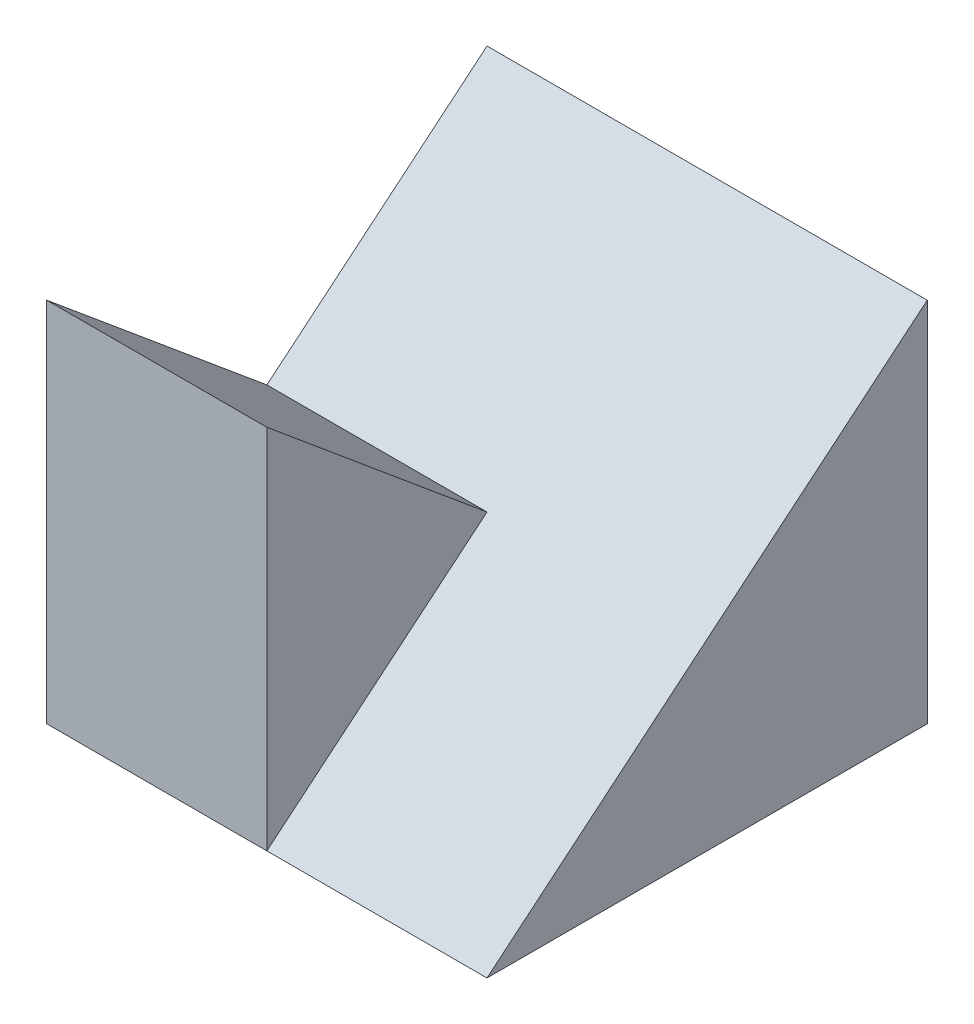
from build123d import *

# Parameters (mm, degrees)
SKETCH1_W           = 6
SKETCH1_H           = 6
BOSS_EXTRUDE1_DEPTH = 5
CUT_EXTRUDE1_DEPTH  = 10
CUT_EXTRUDE2_DEPTH  = 3


with BuildPart() as part:
    # Sketch1 → Boss-Extrude1 (new body)
    with BuildSketch(Plane(origin=(0, 0, 0), x_dir=(1, 0, 0), z_dir=(0, 1, 0))):
        Rectangle(SKETCH1_W, SKETCH1_H)
    extrude(amount=BOSS_EXTRUDE1_DEPTH)

    # Sketch2 → Cut-Extrude1 (cut)
    with BuildSketch(Plane.ZY.offset(3)):
        Polygon((3, 5), (-3, 5), (0, 2.5), align=None)
    extrude(amount=-CUT_EXTRUDE1_DEPTH, mode=Mode.SUBTRACT)

    # Sketch3 → Cut-Extrude2 (cut)
    with BuildSketch(Plane(origin=(3, 0, 0), x_dir=(0, 0, -1), z_dir=(1, 0, 0))):
        Polygon((-3, 0), (0, 2.5), (-3, 5), align=None)
    extrude(amount=-CUT_EXTRUDE2_DEPTH, mode=Mode.SUBTRACT)


solid = part.part
